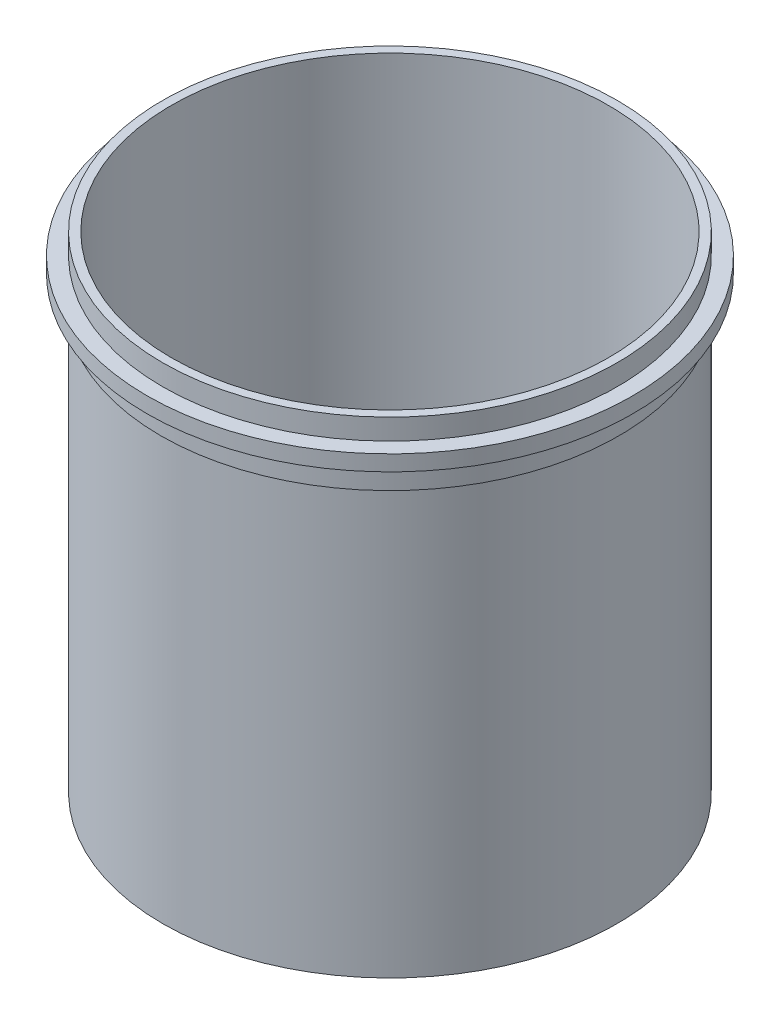
from build123d import *

# Parameters (mm, degrees)
SKETCH1_R           = 131
SKETCH1_R_2         = 126
BOSS_EXTRUDE1_DEPTH = 280
SKETCH4_R           = 140
SKETCH4_R_2         = 131
BOSS_EXTRUDE2_DEPTH = 9
CHAMFER1_SIZE       = 20
CHAMFER1_SIZE2      = 3.526539614
SKETCH5_R           = 132
SKETCH5_R_2         = 131
BOSS_EXTRUDE3_DEPTH = 15


with BuildPart() as part:
    # Sketch1 → Boss-Extrude1 (new body)
    with BuildSketch(Plane(origin=(0, 0, 0), x_dir=(1, 0, 0), z_dir=(0, 1, 0))):
        Circle(SKETCH1_R)
        Circle(SKETCH1_R_2, mode=Mode.SUBTRACT)
    extrude(amount=-BOSS_EXTRUDE1_DEPTH)

    # Sketch4 → Boss-Extrude2 (add)
    with BuildSketch(Plane(origin=(0, -12, 0), x_dir=(1, 0, 0), z_dir=(0, 1, 0))):
        Circle(SKETCH4_R)
        Circle(SKETCH4_R_2, mode=Mode.SUBTRACT)
    extrude(amount=-BOSS_EXTRUDE2_DEPTH)

    # Chamfer1
    chamfer1_edges = [part.edges().sort_by_distance(p)[0] for p in [
        (-126, -280, 0),
    ]]
    chamfer1_side = [part.faces().sort_by_distance(p)[0] for p in [
        (-126, -140, 0),
    ]]
    chamfer(chamfer1_edges, length=CHAMFER1_SIZE, length2=CHAMFER1_SIZE2, reference=chamfer1_side[0])

    # Sketch5 → Boss-Extrude3 (add)
    with BuildSketch(Plane.XZ.offset(21)):
        Circle(SKETCH5_R)
        Circle(SKETCH5_R_2, mode=Mode.SUBTRACT)
    extrude(amount=BOSS_EXTRUDE3_DEPTH)


solid = part.part
